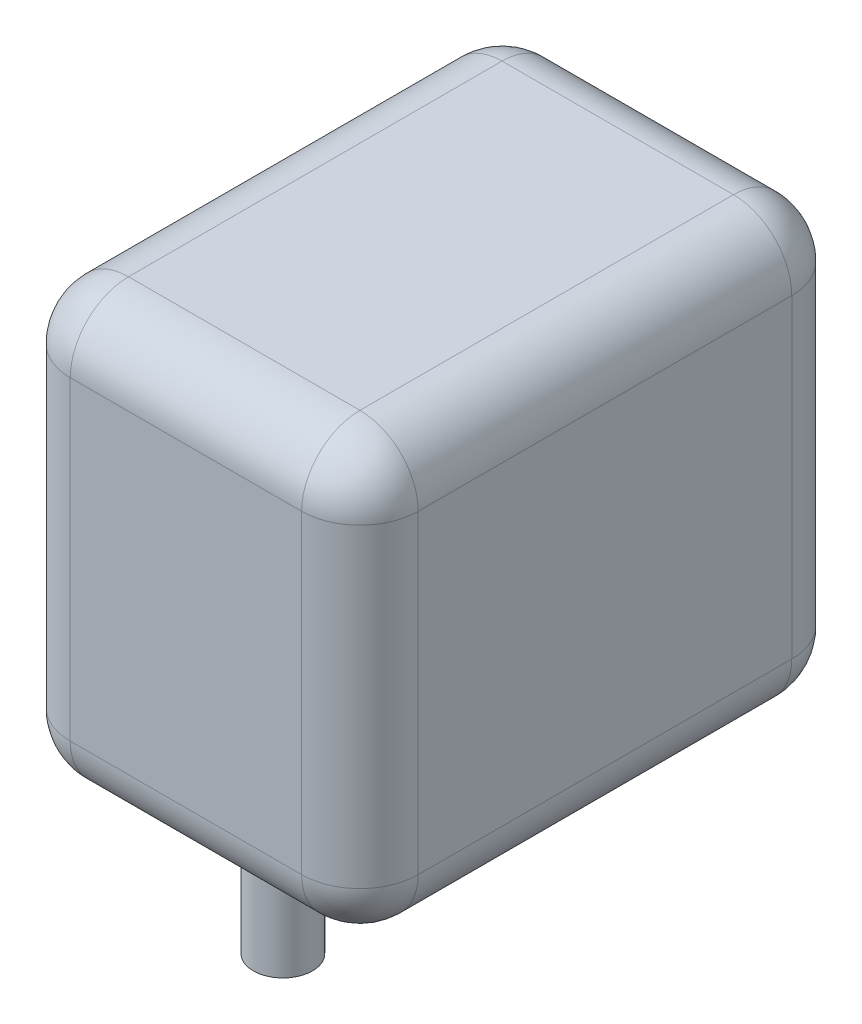
from build123d import *

# Parameters (mm, degrees)
SKETCH3_W           = 59.69
SKETCH3_H           = 84.074
BOSS_EXTRUDE1_DEPTH = 93.98
SKETCH4_W           = 59.69
SKETCH4_H           = 84.074
SKETCH4_R           = 5.08
CUT_EXTRUDE1_DEPTH  = 20
FILLET1_R           = 10


with BuildPart() as part:
    # Sketch3 → Boss-Extrude1 (new body)
    with BuildSketch(Plane(origin=(0, 0, 0), x_dir=(1, 0, 0), z_dir=(0, 1, 0))):
        Rectangle(SKETCH3_W, SKETCH3_H)
    extrude(amount=BOSS_EXTRUDE1_DEPTH)

    # Sketch4 → Cut-Extrude1 (cut)
    with BuildSketch(Plane.XZ):
        Rectangle(SKETCH4_W, SKETCH4_H)
        with Locations((0, 25.4)):
            Circle(SKETCH4_R, mode=Mode.SUBTRACT)
    extrude(amount=-CUT_EXTRUDE1_DEPTH, mode=Mode.SUBTRACT)

    # Fillet1
    fillet1_edges = [part.edges().sort_by_distance(p)[0] for p in [
        (-29.845, 93.98, 0),
        (0, 93.98, 42.037),
        (0, 20, -42.037),
        (-29.845, 20, 0),
        (0, 20, 42.037),
        (29.845, 20, 0),
        (29.845, 93.98, 0),
        (0, 93.98, -42.037),
        (29.845, 56.99, 42.037),
        (-29.845, 56.99, 42.037),
        (-29.845, 56.99, -42.037),
        (29.845, 56.99, -42.037),
    ]]
    fillet(fillet1_edges, radius=FILLET1_R)


solid = part.part
